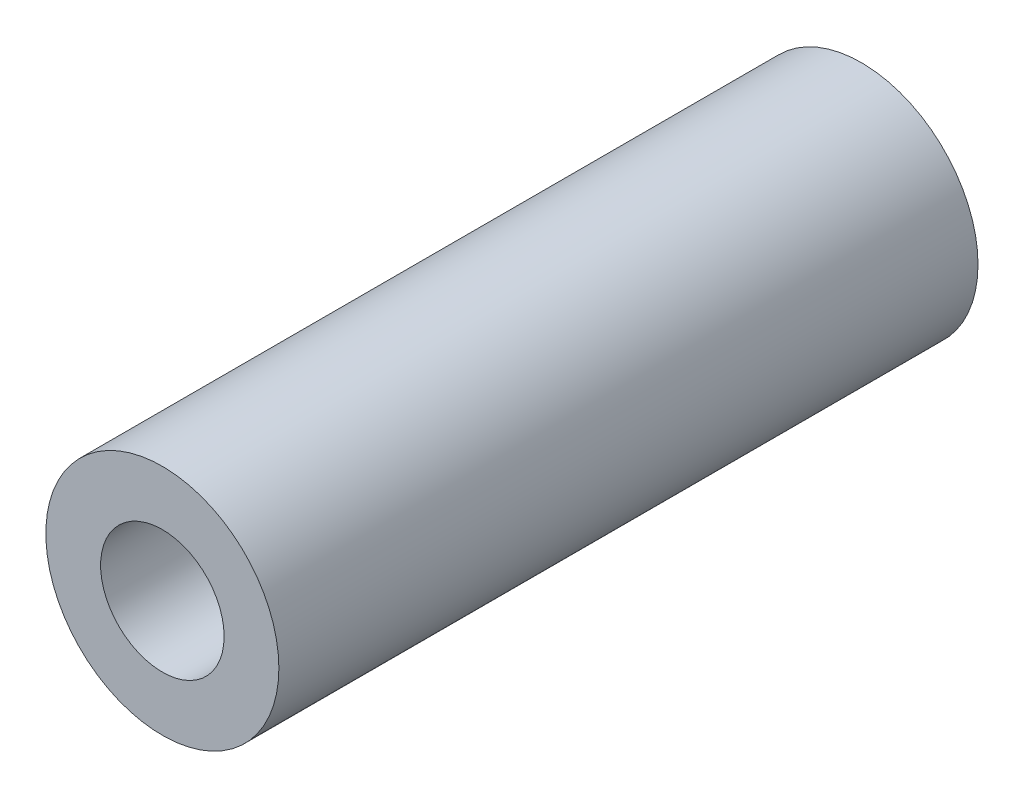
from build123d import *

# Parameters (mm, degrees)
SKETCH1_R      = 5
SKETCH1_R_2    = 2.65
EXTRUDE1_DEPTH = 15


with BuildPart() as part:
    # Sketch1 → Extrude1 (new body, symmetric)
    with BuildSketch(Plane.XY):
        Circle(SKETCH1_R)
        Circle(SKETCH1_R_2, mode=Mode.SUBTRACT)
    extrude(amount=EXTRUDE1_DEPTH, both=True)


solid = part.part
